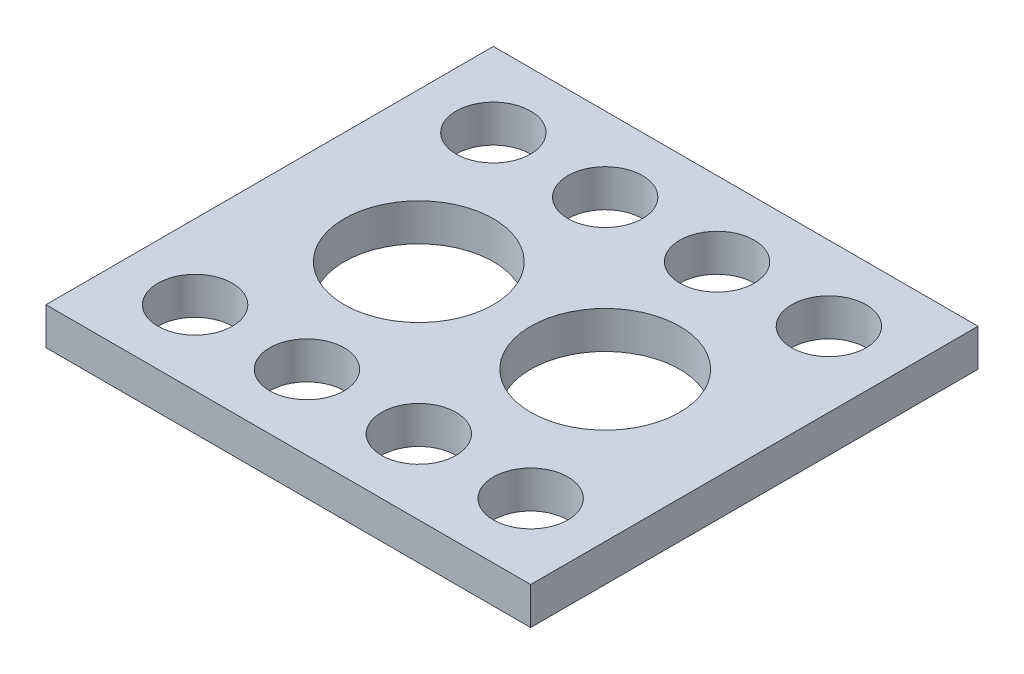
from build123d import *

# Parameters (mm, degrees)
SKETCH1_W           = 165.1
SKETCH1_H           = 152.4
SKETCH1_R           = 12.7
SKETCH1_R_2         = 25.4
BOSS_EXTRUDE1_DEPTH = 12.7


with BuildPart() as part:
    # Sketch1 → Boss-Extrude1 (new body)
    with BuildSketch(Plane(origin=(0, 0, 0), x_dir=(1, 0, 0), z_dir=(0, 1, 0))):
        with Locations((82.55, 76.2)):
            Rectangle(SKETCH1_W, SKETCH1_H)
        with Locations((25.4, 127)):
            Circle(SKETCH1_R, mode=Mode.SUBTRACT)
        with Locations((63.5, 127)):
            Circle(SKETCH1_R, mode=Mode.SUBTRACT)
        with Locations((101.6, 127)):
            Circle(SKETCH1_R, mode=Mode.SUBTRACT)
        with Locations((139.7, 127)):
            Circle(SKETCH1_R, mode=Mode.SUBTRACT)
        with Locations((25.4, 25.4)):
            Circle(SKETCH1_R, mode=Mode.SUBTRACT)
        with Locations((63.5, 25.4)):
            Circle(SKETCH1_R, mode=Mode.SUBTRACT)
        with Locations((101.6, 25.4)):
            Circle(SKETCH1_R, mode=Mode.SUBTRACT)
        with Locations((139.7, 25.4)):
            Circle(SKETCH1_R, mode=Mode.SUBTRACT)
        with Locations((50.8, 76.2)):
            Circle(SKETCH1_R_2, mode=Mode.SUBTRACT)
        with Locations((114.3, 76.2)):
            Circle(SKETCH1_R_2, mode=Mode.SUBTRACT)
    extrude(amount=BOSS_EXTRUDE1_DEPTH)


solid = part.part
